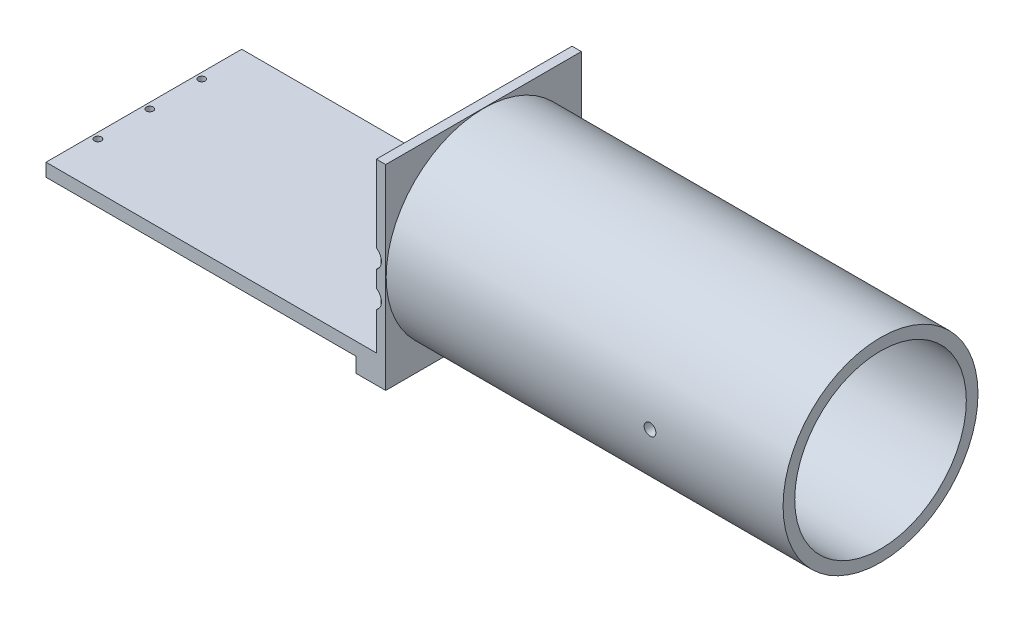
from build123d import *

# Parameters (mm, degrees)
SKETCH3_W                                    = 145.5000011
SKETCH3_H                                    = 83.82
BOSS_EXTRUDE1_DEPTH                          = 83.82
SKETCH4_W                                    = 141.50000148
SKETCH4_H                                    = 79.312008
CUT_EXTRUDE1_DEPTH                           = 71.882
CBORE_FOR_M3_HEX_HEAD_CAP_SCREW1_D           = 3.4
CBORE_FOR_M3_HEX_HEAD_CAP_SCREW1_DEPTH       = 3.99999962
CBORE_FOR_M3_HEX_HEAD_CAP_SCREW1_CBORE_D     = 9.351
CBORE_FOR_M3_HEX_HEAD_CAP_SCREW1_CBORE_DEPTH = 2
CUT_EXTRUDE3_REACH                           = 147.5
SKETCH5_R                                    = 12.7
CBORE_FOR_M3_HEX_HEAD_CAP_SCREW2_D           = 3.4
CBORE_FOR_M3_HEX_HEAD_CAP_SCREW2_DEPTH       = 4.507992
CBORE_FOR_M3_HEX_HEAD_CAP_SCREW2_CBORE_D     = 9.351
CBORE_FOR_M3_HEX_HEAD_CAP_SCREW2_CBORE_DEPTH = 2
F_3_0MM_DOWEL_HOLE1_D                        = 3
F_3_0MM_DOWEL_HOLE1_DEPTH                    = 4.507992
F_3_0MM_DOWEL_HOLE2_D                        = 3
F_3_0MM_DOWEL_HOLE2_DEPTH                    = 11.938
CBORE_FOR_M3_HEX_HEAD_CAP_SCREW3_D           = 3.4
CBORE_FOR_M3_HEX_HEAD_CAP_SCREW3_DEPTH       = 11.938
CBORE_FOR_M3_HEX_HEAD_CAP_SCREW3_CBORE_D     = 9.351
CBORE_FOR_M3_HEX_HEAD_CAP_SCREW3_CBORE_DEPTH = 2
SKETCH22_R                                   = 41.75000032
BOSS_EXTRUDE3_DEPTH                          = 170
SKETCH26_R                                   = 36.75001032
CUT_EXTRUDE5_DEPTH                           = 170
SKETCH27_W                                   = 141.50000148
SKETCH27_H                                   = 4.507992
CUT_EXTRUDE7_DEPTH                           = 71.882
SKETCH28_W                                   = 132.727764313
SKETCH28_H                                   = 83.82
CUT_EXTRUDE8_DEPTH                           = 6.35
TAP_DRILL_FOR_M6_TAP2_D                      = 5


with BuildPart() as part:
    # Sketch3 → Boss-Extrude1 (new body)
    with BuildSketch(Plane(origin=(0, 0, 0), x_dir=(1, 0, 0), z_dir=(0, 1, 0))):
        with Locations((33.920258223, -7.464260839)):
            Rectangle(SKETCH3_W, SKETCH3_H)
    extrude(amount=BOSS_EXTRUDE1_DEPTH)

    # Sketch4 → Cut-Extrude1 (cut)
    with BuildSketch(Plane(origin=(0, 83.82, 0), x_dir=(1, 0, 0), z_dir=(0, 1, 0))):
        with Locations((31.920258413, -5.210264839)):
            Rectangle(SKETCH4_W, SKETCH4_H)
    extrude(amount=-CUT_EXTRUDE1_DEPTH, mode=Mode.SUBTRACT)

    # CBORE for M3 Hex Head Cap Screw1
    with Locations(Plane(origin=(106.670258773, 0, 0), x_dir=(0, 0, -1), z_dir=(1, 0, 0))):
        with Locations((-32.411268839, 54.438), (17.588731161, 54.438), (17.588731161, 29.438), (-32.411268839, 29.438)):
            CounterBoreHole(CBORE_FOR_M3_HEX_HEAD_CAP_SCREW1_D / 2, CBORE_FOR_M3_HEX_HEAD_CAP_SCREW1_CBORE_D / 2, CBORE_FOR_M3_HEX_HEAD_CAP_SCREW1_CBORE_DEPTH, depth=CBORE_FOR_M3_HEX_HEAD_CAP_SCREW1_DEPTH)

    # Sketch5 → Cut-Extrude3 (cut, up to next)
    with BuildSketch(Plane(origin=(106.670258773, 0, 0), x_dir=(0, 0, -1), z_dir=(1, 0, 0)), mode=Mode.PRIVATE) as cut_extrude3_sk1:
        with Locations((-7.411268839, 41.938)):
            Circle(SKETCH5_R)
    cut_extrude3_tool1 = extrude(cut_extrude3_sk1.sketch, amount=-CUT_EXTRUDE3_REACH, mode=Mode.PRIVATE) & part.part
    add(cut_extrude3_tool1.solids().sort_by_distance((106.670259, 41.938, 7.411269))[0], mode=Mode.SUBTRACT)

    # CBORE for M3 Hex Head Cap Screw2
    with Locations(Plane.XY.offset(49.374260839)):
        with Locations((100.170259153, 46.938), (100.170259153, 31.938)):
            CounterBoreHole(CBORE_FOR_M3_HEX_HEAD_CAP_SCREW2_D / 2, CBORE_FOR_M3_HEX_HEAD_CAP_SCREW2_CBORE_D / 2, CBORE_FOR_M3_HEX_HEAD_CAP_SCREW2_CBORE_DEPTH, depth=CBORE_FOR_M3_HEX_HEAD_CAP_SCREW2_DEPTH)

    # Ø3.0mm Dowel Hole1
    with Locations(Plane.XY.offset(49.374260839)):
        with Locations((-36.329740847, 46.938), (-36.329740847, 31.938)):
            Hole(F_3_0MM_DOWEL_HOLE1_D / 2, depth=F_3_0MM_DOWEL_HOLE1_DEPTH)

    # Ø3.0mm Dowel Hole2
    with Locations(Plane(origin=(0, 0, 0), x_dir=(-1, 0, 0), z_dir=(0, -1, 0))):
        with Locations((36.329740847, -29.661268839), (36.329740847, -7.411268839), (36.329740847, 14.838731161)):
            Hole(F_3_0MM_DOWEL_HOLE2_D / 2, depth=F_3_0MM_DOWEL_HOLE2_DEPTH)

    # CBORE for M3 Hex Head Cap Screw3
    with Locations(Plane(origin=(0, 0, 0), x_dir=(-1, 0, 0), z_dir=(0, -1, 0))):
        with Locations((-100.170259153, -29.661268839), (-100.170259153, -7.411268839), (-100.170259153, 14.838731161)):
            CounterBoreHole(CBORE_FOR_M3_HEX_HEAD_CAP_SCREW3_D / 2, CBORE_FOR_M3_HEX_HEAD_CAP_SCREW3_CBORE_D / 2, CBORE_FOR_M3_HEX_HEAD_CAP_SCREW3_CBORE_DEPTH, depth=CBORE_FOR_M3_HEX_HEAD_CAP_SCREW3_DEPTH)

    # Sketch22 → Boss-Extrude3 (add)
    with BuildSketch(Plane(origin=(106.670258773, 0, 0), x_dir=(0, 0, -1), z_dir=(1, 0, 0))):
        with Locations((-7.411268839, 41.938)):
            Circle(SKETCH22_R)
    extrude(amount=BOSS_EXTRUDE3_DEPTH)

    # Sketch26 → Cut-Extrude5 (cut)
    with BuildSketch(Plane(origin=(276.670258773, 0, 0), x_dir=(0, 0, -1), z_dir=(1, 0, 0))):
        with Locations((-7.411268839, 41.938)):
            Circle(SKETCH26_R)
    extrude(amount=-CUT_EXTRUDE5_DEPTH, mode=Mode.SUBTRACT)

    # Sketch27 → Cut-Extrude7 (cut)
    with BuildSketch(Plane(origin=(0, 83.82, 0), x_dir=(1, 0, 0), z_dir=(0, 1, 0))):
        with Locations((31.920258413, -47.120264839)):
            Rectangle(SKETCH27_W, SKETCH27_H)
    extrude(amount=-CUT_EXTRUDE7_DEPTH, mode=Mode.SUBTRACT)

    # Sketch28 → Cut-Extrude8 (cut)
    with BuildSketch(Plane(origin=(0, 0, 0), x_dir=(-1, 0, 0), z_dir=(0, -1, 0))):
        with Locations((-27.534139829, -7.464260839)):
            Rectangle(SKETCH28_W, SKETCH28_H)
    extrude(amount=-CUT_EXTRUDE8_DEPTH, mode=Mode.SUBTRACT)

    # Tap Drill for M6 Tap2 (through all)
    with Locations(Plane(origin=(191.670258773, 41.938, -34.338731481), x_dir=(-1, 0, 0), z_dir=(0, 0, -1))):
        with Locations((-28, 0)):
            Hole(TAP_DRILL_FOR_M6_TAP2_D / 2)


solid = part.part
